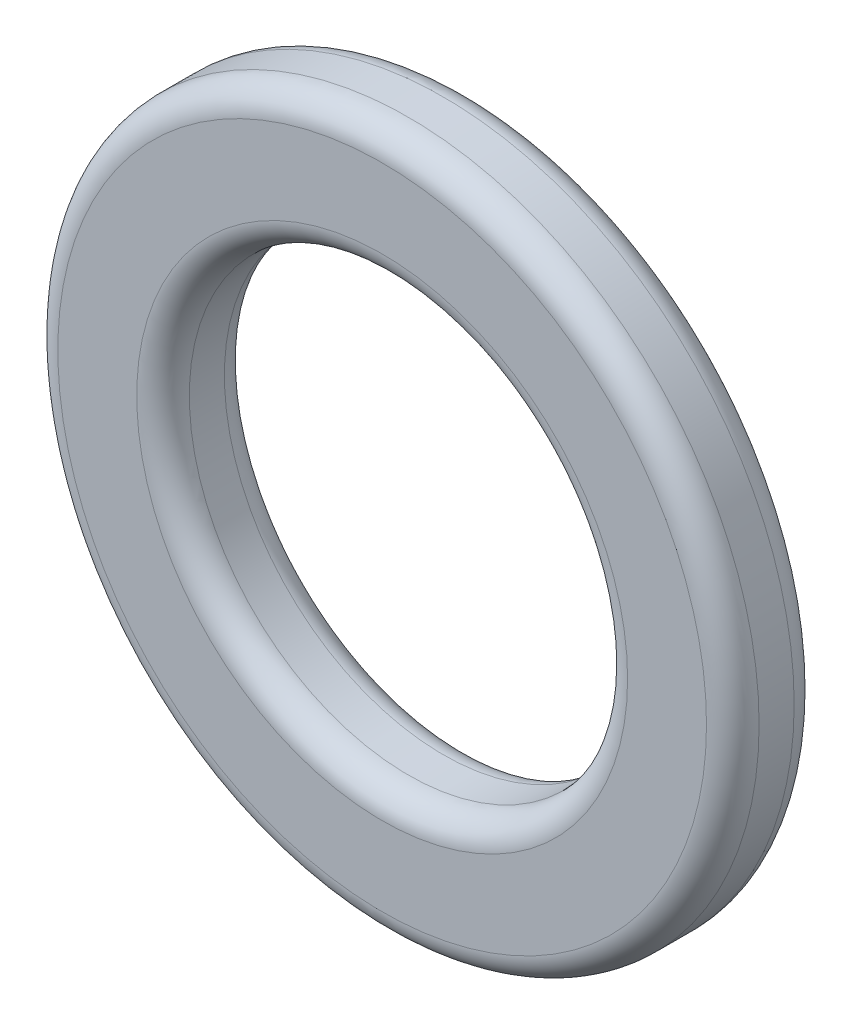
from build123d import *

# Parameters (mm, degrees)
SCHIZZO1_R                   = 4
SCHIZZO1_R_2                 = 2.5
ESTRUSIONE_ESTRUSIONE1_DEPTH = 1
RACCORDO1_R                  = 0.3


with BuildPart() as part:
    # Schizzo1 → Estrusione-Estrusione1 (new body)
    with BuildSketch(Plane.XY):
        Circle(SCHIZZO1_R)
        Circle(SCHIZZO1_R_2, mode=Mode.SUBTRACT)
    extrude(amount=ESTRUSIONE_ESTRUSIONE1_DEPTH)

    # Raccordo1
    raccordo1_edges = [part.edges().sort_by_distance(p)[0] for p in [
        (-4, 0, 0),
        (-4, 0, 1),
        (-2.5, 0, 0),
        (-2.5, 0, 1),
    ]]
    fillet(raccordo1_edges, radius=RACCORDO1_R)


solid = part.part
